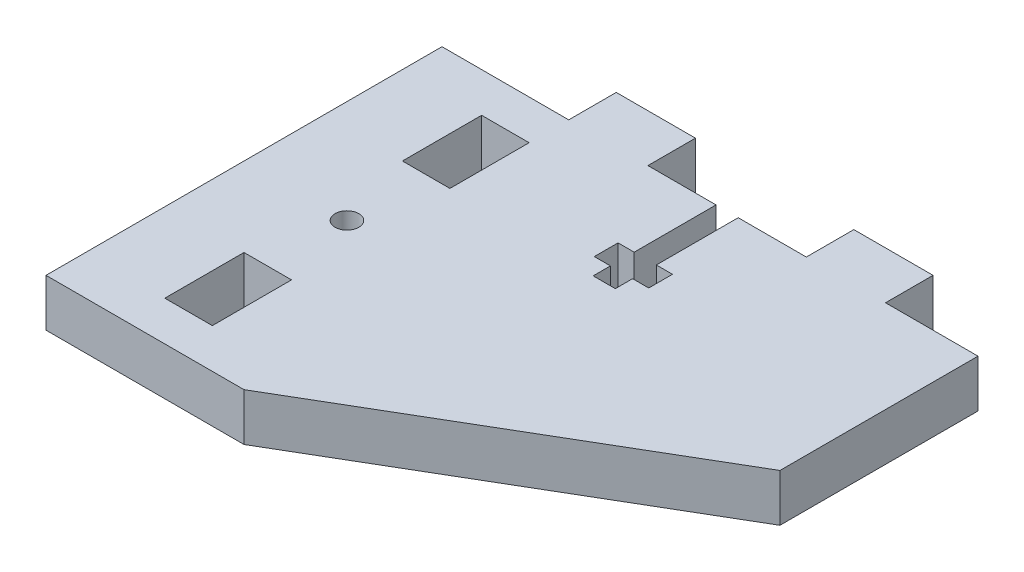
from build123d import *

# Parameters (mm, degrees)
SKETCH_1_R      = 1.5
SKETCH_1_W      = 6
SKETCH_1_H      = 10
EXTRUDE_2_DEPTH = 6


with BuildPart() as part:
    # Эскиз1 → Бобышка-Вытянуть2 (new body)
    with BuildSketch(Plane(origin=(0, 0, 0), x_dir=(1, 0, 0), z_dir=(0, 1, 0))):
        Polygon((-3.416793382, 32.742423734), (5.183206618, 32.742423734), (5.183206618, 22.407164878), (3.146696627, 22.407214255), (3.146623876, 19.406616385), (5.182814398, 19.407762757), (5.184095658, 17.225944952), (7.984095175, 17.227589235), (7.982815638, 19.406473379), (10.020338121, 19.407669902), (10.020410843, 22.407047597), (7.983206618, 22.40709699), (7.983206618, 32.742423734), (16.583206618, 32.742423734), (16.583206618, 38.742423734), (26.583206618, 38.742423734), (26.583206618, 32.742423734), (38.259419898, 32.742423734), (38.255234849, 7.742423734), (-4.416793382, -17.257576266), (-29.416793382, -17.257576266), (-29.416793382, 32.742423734), (-13.416793382, 32.742423734), (-13.416793382, 38.742423734), (-3.416793382, 38.742423734), align=None)
        with Locations((-16.416793382, 7.742423734)):
            Circle(SKETCH_1_R, mode=Mode.SUBTRACT)
        with Locations((-16.416793382, 22.742423734)):
            Rectangle(SKETCH_1_W, SKETCH_1_H, mode=Mode.SUBTRACT)
        with Locations((-16.416793382, -7.257576266)):
            Rectangle(SKETCH_1_W, SKETCH_1_H, mode=Mode.SUBTRACT)
    extrude(amount=EXTRUDE_2_DEPTH)


solid = part.part
